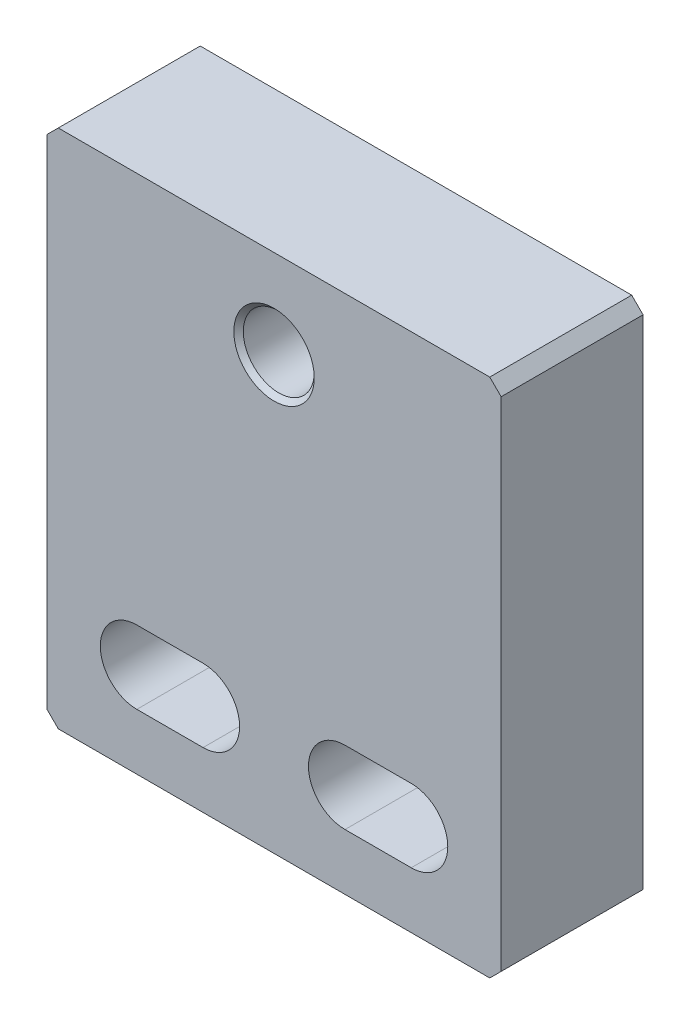
from build123d import *

# Parameters (mm, degrees)
BOSS_EXTRUDE1_DEPTH               = 19.05
F_3_8_16_TAPPED_HOLE1_D           = 9.525
F_3_8_16_TAPPED_HOLE1_CSINK_D     = 10.795
F_3_8_16_TAPPED_HOLE1_CSINK_ANGLE = 90


with BuildPart() as part:
    # Sketch6 → Boss-Extrude1 (new body)
    with BuildSketch(Plane.XY):
        Polygon((-28.956, 57.404), (28.956, 57.404), (30.48, 55.88), (30.48, -10.922), (28.956, -12.446), (-28.956, -12.446), (-30.48, -10.922), (-30.48, 55.88), align=None)
        with BuildLine():
            Line((9.525, 4.9022), (18.415, 4.9022))
            ThreePointArc((18.415, 4.9022), (23.3172, 0), (18.415, -4.9022))
            Line((18.415, -4.9022), (9.525, -4.9022))
            ThreePointArc((9.525, -4.9022), (4.6228, 0), (9.525, 4.9022))
        make_face(mode=Mode.SUBTRACT)
        with BuildLine():
            Line((-9.525, 4.9022), (-18.415, 4.9022))
            ThreePointArc((-18.415, 4.9022), (-23.3172, 0), (-18.415, -4.9022))
            Line((-18.415, -4.9022), (-9.525, -4.9022))
            ThreePointArc((-9.525, -4.9022), (-4.6228, 0), (-9.525, 4.9022))
        make_face(mode=Mode.SUBTRACT)
    extrude(amount=-BOSS_EXTRUDE1_DEPTH)

    # 3/8-16 Tapped Hole1 (through all)
    with Locations(Plane.XY):
        with Locations((0, 45.5295)):
            CounterSinkHole(F_3_8_16_TAPPED_HOLE1_D / 2, F_3_8_16_TAPPED_HOLE1_CSINK_D / 2, counter_sink_angle=F_3_8_16_TAPPED_HOLE1_CSINK_ANGLE)


solid = part.part
